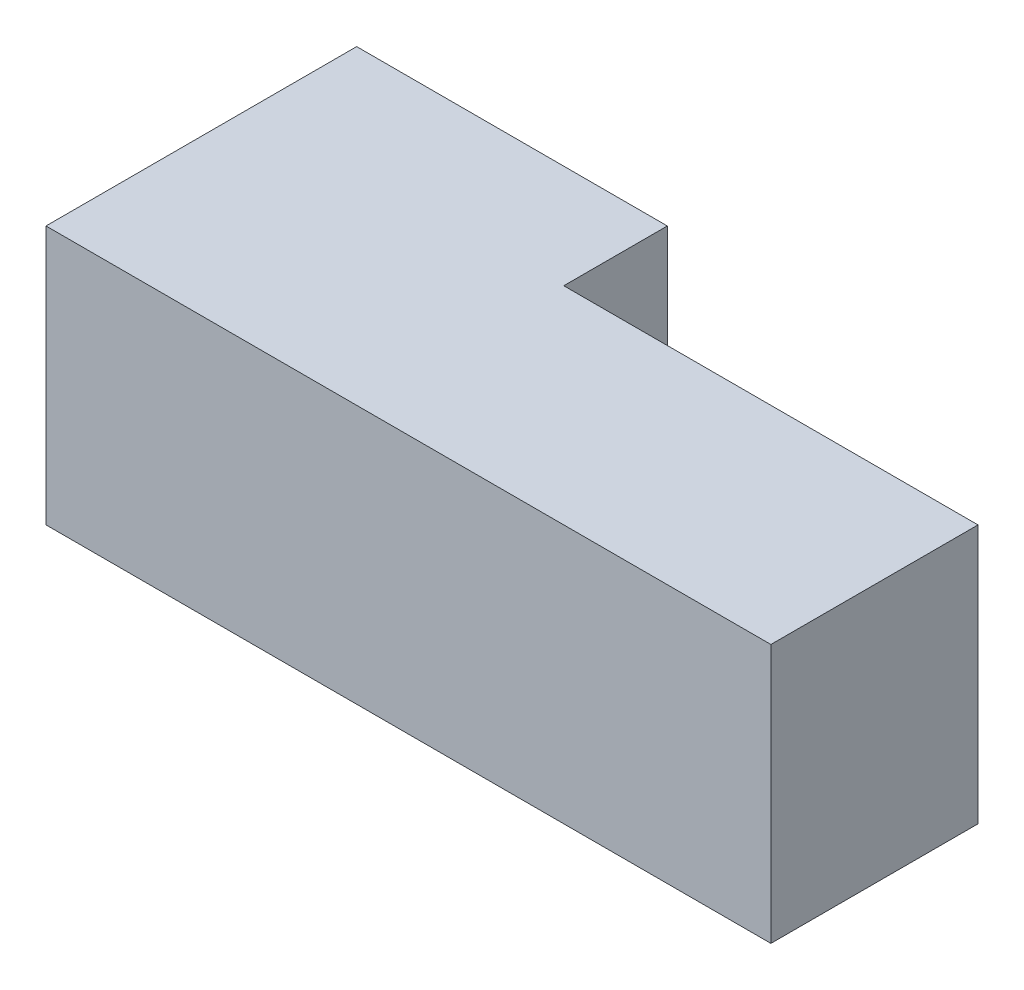
from build123d import *

# Parameters (mm, degrees)
BOSS_EXTRUDE1_DEPTH = 25


with BuildPart() as part:
    # Sketch1 → Boss-Extrude1 (new body)
    with BuildSketch(Plane(origin=(0, 0, 0), x_dir=(1, 0, 0), z_dir=(0, 1, 0))):
        Polygon((30, 30), (30, 20), (70, 20), (70, 0), (0, 0), (0, 30), align=None)
    extrude(amount=BOSS_EXTRUDE1_DEPTH)


solid = part.part
